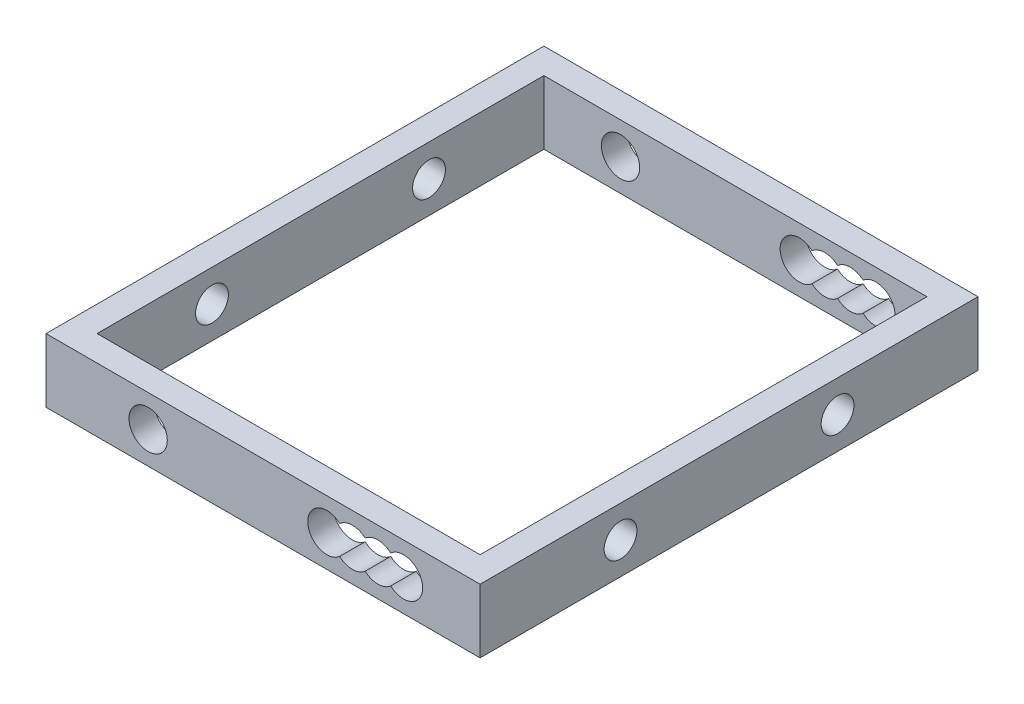
from build123d import *

# Parameters (mm, degrees)
ESBO_O1_W                = 30
ESBO_O1_H                = 5
ESBO_O1_R                = 1.5
RESSALTO_EXTRUS_O1_DEPTH = 2
ESBO_O3_W                = 2
ESBO_O3_H                = 5
RESSALTO_EXTRUS_O2_DEPTH = 39
PADR_O_LINEAR1_COUNT     = 2
PADR_O_LINEAR1_PITCH     = 37
ESBO_O4_R                = 1.285304246
CORTE_EXTRUS_O1_DEPTH    = 39


with BuildPart() as part:
    # Esboço1 → Ressalto-extrusão1 (new body)
    with BuildSketch(Plane.XY):
        Rectangle(ESBO_O1_W, ESBO_O1_H)
        with Locations((-9, 0)):
            Circle(ESBO_O1_R, mode=Mode.SUBTRACT)
        with BuildLine():
            ThreePointArc((6, 1.118033989), (3.5, 0), (6, -1.118033989))
            ThreePointArc((6, -1.118033989), (7, -1.5), (8, -1.118033989))
            ThreePointArc((8, -1.118033989), (9, -1.5), (10, -1.118033989))
            ThreePointArc((10, -1.118033989), (12.5, 0), (10, 1.118033989))
            ThreePointArc((10, 1.118033989), (9, 1.5), (8, 1.118033989))
            ThreePointArc((8, 1.118033989), (7, 1.5), (6, 1.118033989))
        make_face(mode=Mode.SUBTRACT)
    ressalto_extrus_o1 = extrude(amount=RESSALTO_EXTRUS_O1_DEPTH)

    # Esboço3 → Ressalto-extrusão2 (add)
    with BuildSketch(Plane.XY.offset(2)):
        with Locations((16, 0)):
            Rectangle(ESBO_O3_W, ESBO_O3_H)
    ressalto_extrus_o2 = extrude(amount=-RESSALTO_EXTRUS_O2_DEPTH)

    # Padrão linear1: Ressalto-extrusão1 ×2
    with Locations(*[(0, 0, -i * PADR_O_LINEAR1_PITCH) for i in range(1, PADR_O_LINEAR1_COUNT)]):
        add(ressalto_extrus_o1)

    # Espelhar1: Ressalto-extrusão2 across plane
    add(ressalto_extrus_o2.mirror(Plane(origin=(0, 0, 0), x_dir=(0, 0, 1), z_dir=(1, 0, 0))))

    # Esboço4 → Corte-extrusão1 (cut)
    with BuildSketch(Plane(origin=(17, 0, 0), x_dir=(0, 0, -1), z_dir=(1, 0, 0))):
        with Locations((9, 0)):
            Circle(ESBO_O4_R)
        with Locations((26, 0)):
            Circle(ESBO_O4_R)
    extrude(amount=-CORTE_EXTRUS_O1_DEPTH, mode=Mode.SUBTRACT)


solid = part.part
